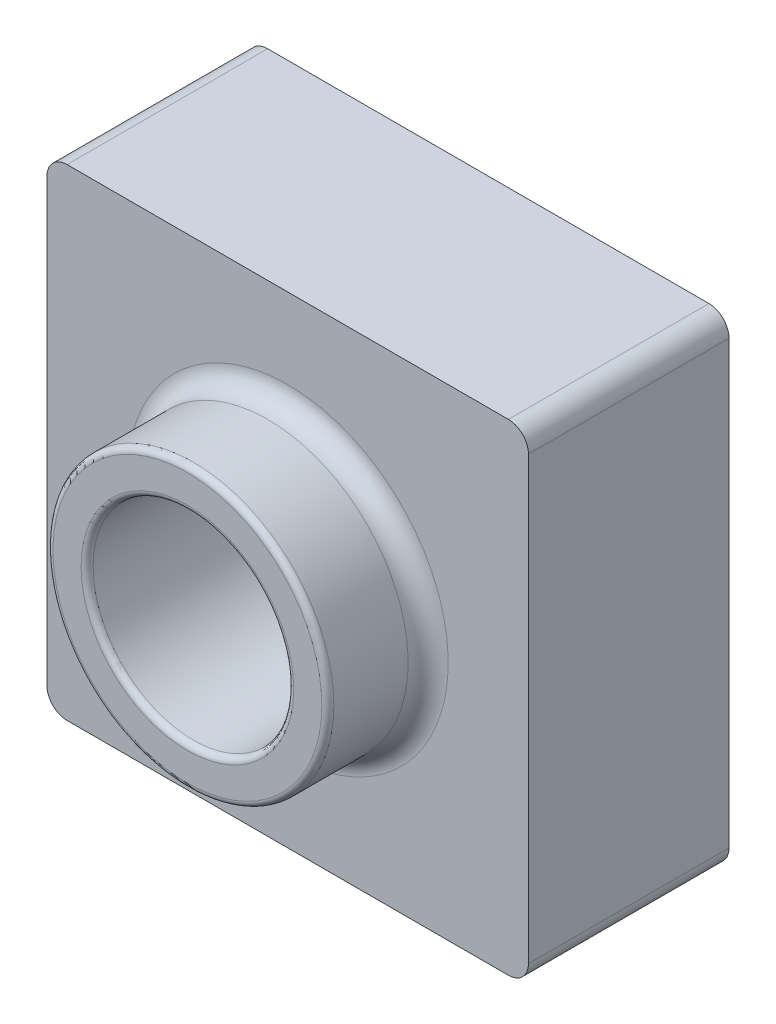
from build123d import *

# Parameters (mm, degrees)
SKETCH1_W           = 3048
SKETCH1_H           = 3048
BOSS_EXTRUDE1_DEPTH = 1270
SKETCH3_R           = 889
BOSS_EXTRUDE2_DEPTH = 635
SKETCH8_R           = 635
CUT_EXTRUDE1_DEPTH  = 4713.709730081
FILLET11_R          = 127
FILLET12_R          = 38.1
SHELL1_T            = -50.8
FILLET13_R          = 127


with BuildPart() as part:
    # Sketch1 → Boss-Extrude1 (new body)
    with BuildSketch(Plane.XY):
        with Locations((1524, 1524)):
            Rectangle(SKETCH1_W, SKETCH1_H)
    extrude(amount=-BOSS_EXTRUDE1_DEPTH)

    # Sketch3 → Boss-Extrude2 (add)
    with BuildSketch(Plane.XY):
        with Locations(Location((1524, 1524, 0), (0, 0, 180))):
            Circle(SKETCH3_R)
    extrude(amount=BOSS_EXTRUDE2_DEPTH)

    # Sketch8 → Cut-Extrude1 (cut, through all)
    with BuildSketch(Plane.XY.offset(635)):
        with Locations((1524, 1524)):
            Circle(SKETCH8_R)
    extrude(amount=-CUT_EXTRUDE1_DEPTH, mode=Mode.SUBTRACT)

    # Fillet11
    fillet11_edges = [part.edges().sort_by_distance(p)[0] for p in [
        (2413, 1524, 0),
    ]]
    fillet(fillet11_edges, radius=FILLET11_R)

    # Fillet12
    fillet12_edges = [part.edges().sort_by_distance(p)[0] for p in [
        (2413, 1524, 635),
        (889, 1524, 635),
    ]]
    fillet(fillet12_edges, radius=FILLET12_R)

    # Shell1
    shell1_openings = [part.faces().sort_by_distance(p)[0] for p in [
        (1524, 43.105229381, -1270),
    ]]
    offset(amount=SHELL1_T, openings=shell1_openings, kind=Kind.INTERSECTION)

    # Fillet13
    fillet13_edges = [part.edges().sort_by_distance(p)[0] for p in [
        (0, 0, -635),
        (3048, 0, -635),
        (3048, 3048, -635),
        (0, 3048, -635),
    ]]
    fillet(fillet13_edges, radius=FILLET13_R)


solid = part.part
